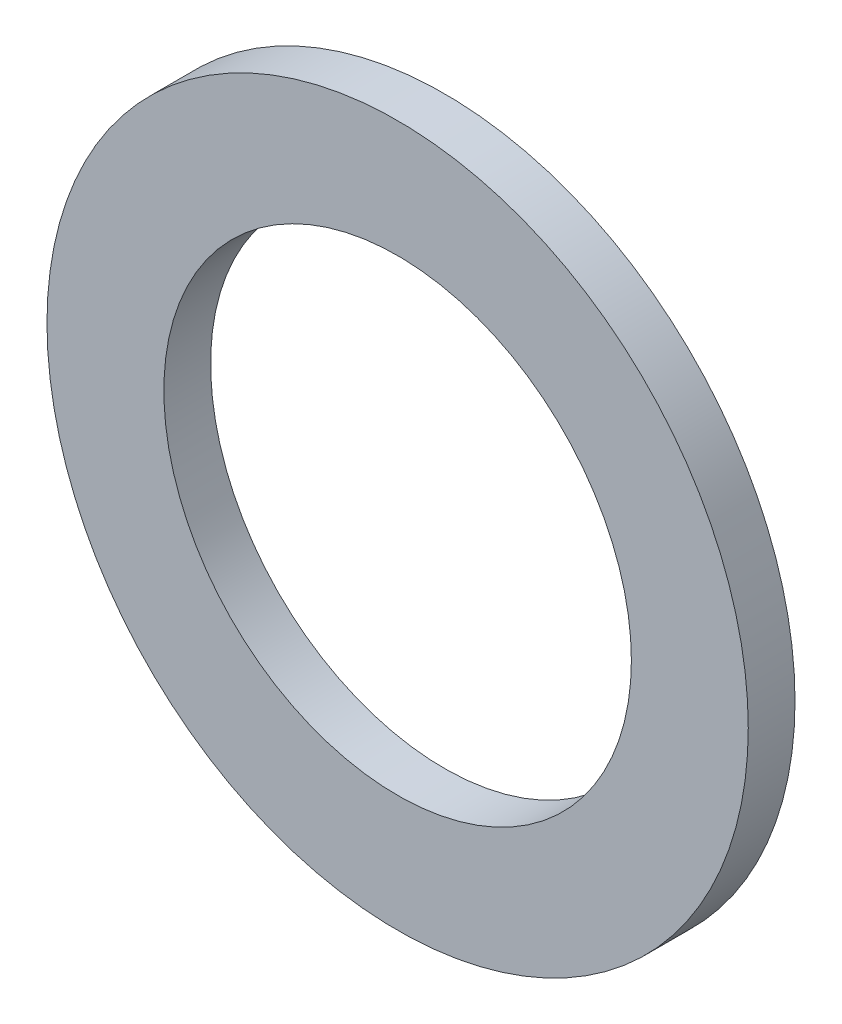
from build123d import *

# Parameters (mm, degrees)
SKETCH1_R           = 9.525
SKETCH1_R_2         = 6.35
BOSS_EXTRUDE1_DEPTH = 1.27


with BuildPart() as part:
    # Sketch1 → Boss-Extrude1 (new body)
    with BuildSketch(Plane.XY):
        Circle(SKETCH1_R)
        Circle(SKETCH1_R_2, mode=Mode.SUBTRACT)
    extrude(amount=BOSS_EXTRUDE1_DEPTH)


solid = part.part
